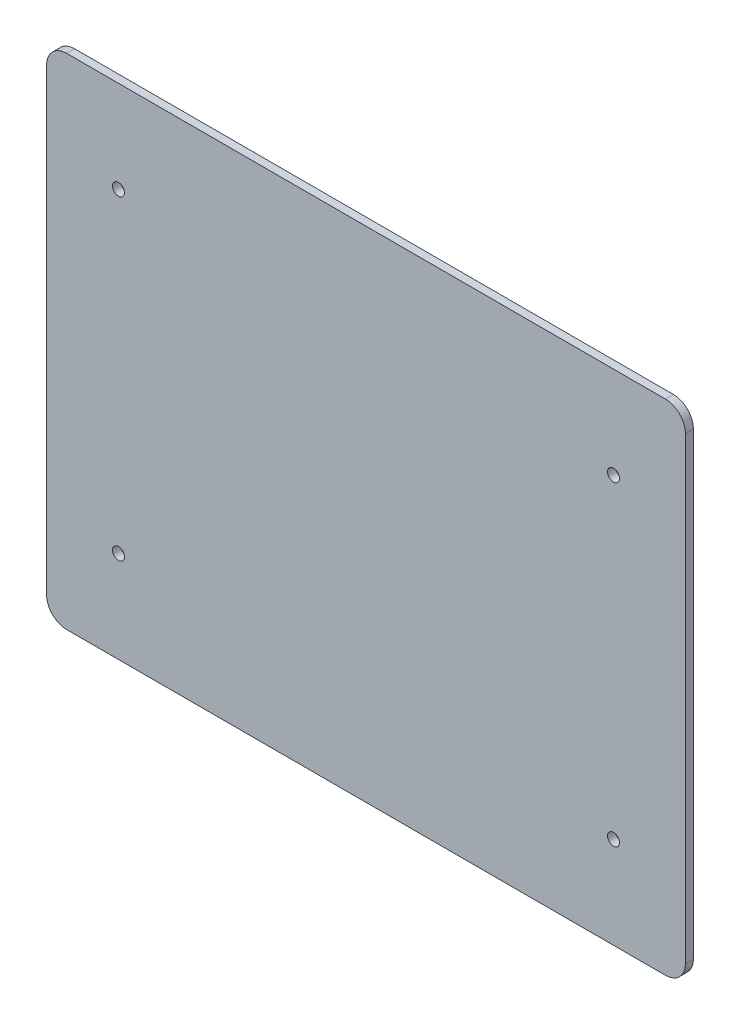
from build123d import *

# Parameters (mm, degrees)
RESSALTO_EXTRUS_O1_DEPTH = 2
ESBO_O2_R                = 1.5
CORTE_EXTRUS_O1_DEPTH    = 10


with BuildPart() as part:
    # Esboço1 → Ressalto-extrusão1 (new body)
    with BuildSketch(Plane.XY):
        with BuildLine():
            Line((47.367635672, -148.027068541), (-102.632364328, -148.027068541))
            ThreePointArc((-102.632364328, -148.027068541), (-106.167898234, -146.562602447), (-107.632364328, -143.027068541))
            Line((-107.632364328, -143.027068541), (-107.632364328, -28.027068541))
            ThreePointArc((-107.632364328, -28.027068541), (-106.167898234, -24.491534635), (-102.632364328, -23.027068541))
            Line((-102.632364328, -23.027068541), (47.367635672, -23.027068541))
            ThreePointArc((47.367635672, -23.027068541), (50.903169578, -24.491534635), (52.367635672, -28.027068541))
            Line((52.367635672, -28.027068541), (52.367635672, -143.027068541))
            ThreePointArc((52.367635672, -143.027068541), (50.903169578, -146.562602447), (47.367635672, -148.027068541))
        make_face()
    extrude(amount=RESSALTO_EXTRUS_O1_DEPTH)

    # Esboço2 → Corte-extrusão1 (cut)
    with BuildSketch(Plane(origin=(0, 0, 0), x_dir=(-1, 0, 0), z_dir=(0, 0, -1))):
        with Locations((-34.367635672, -125.027068541)):
            Circle(ESBO_O2_R)
        with Locations((-34.367635672, -46.027068541)):
            Circle(ESBO_O2_R)
        with Locations((89.632364328, -46.027068541)):
            Circle(ESBO_O2_R)
        with Locations((89.632364328, -125.027068541)):
            Circle(ESBO_O2_R)
    extrude(amount=-CORTE_EXTRUS_O1_DEPTH, mode=Mode.SUBTRACT)


solid = part.part
